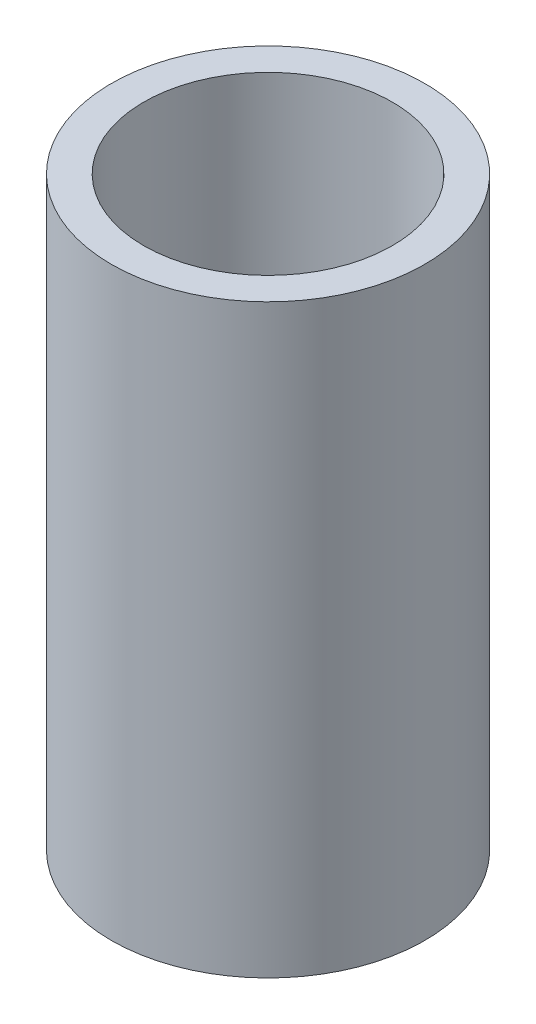
from build123d import *

# Parameters (mm, degrees)
SKETCH1_R           = 4
SKETCH1_R_2         = 3.175
BOSS_EXTRUDE1_DEPTH = 14.948000124


with BuildPart() as part:
    # Sketch1 → Boss-Extrude1 (new body)
    with BuildSketch(Plane(origin=(0, 0, 0), x_dir=(1, 0, 0), z_dir=(0, 1, 0))):
        Circle(SKETCH1_R)
        Circle(SKETCH1_R_2, mode=Mode.SUBTRACT)
    extrude(amount=BOSS_EXTRUDE1_DEPTH)


solid = part.part
